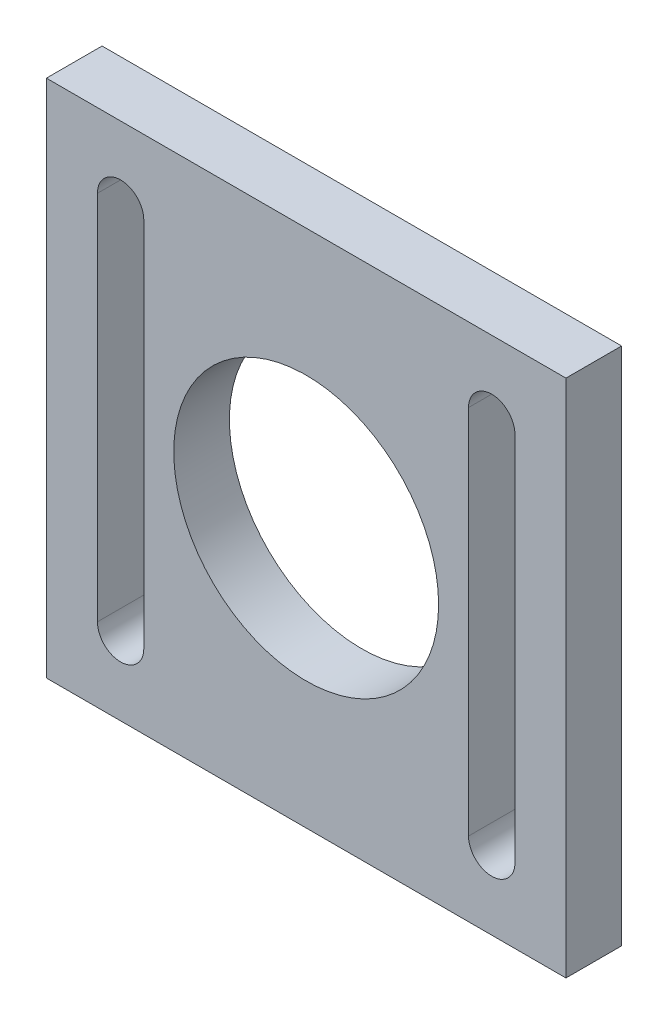
from build123d import *

# Parameters (mm, degrees)
SKETCH1_W           = 56
SKETCH1_H           = 56
BOSS_EXTRUDE1_DEPTH = 6
SKETCH2_R           = 14.275
CUT_EXTRUDE1_DEPTH  = 6


with BuildPart() as part:
    # Sketch1 → Boss-Extrude1 (new body)
    with BuildSketch(Plane.XY):
        with Locations((28, 28)):
            Rectangle(SKETCH1_W, SKETCH1_H)
    extrude(amount=BOSS_EXTRUDE1_DEPTH)

    # Sketch2 → Cut-Extrude1 (cut)
    with BuildSketch(Plane.XY.offset(6)):
        with Locations((28, 28)):
            Circle(SKETCH2_R)
        with BuildLine():
            Line((10.5, 48), (10.5, 8))
            ThreePointArc((10.5, 8), (8, 5.5), (5.5, 8))
            Line((5.5, 8), (5.5, 48))
            ThreePointArc((5.5, 48), (8, 50.5), (10.5, 48))
        make_face()
        with BuildLine():
            Line((50.5, 48), (50.5, 8))
            ThreePointArc((50.5, 8), (48, 5.5), (45.5, 8))
            Line((45.5, 8), (45.5, 48))
            ThreePointArc((45.5, 48), (48, 50.5), (50.5, 48))
        make_face()
    extrude(amount=-CUT_EXTRUDE1_DEPTH, mode=Mode.SUBTRACT)


solid = part.part
